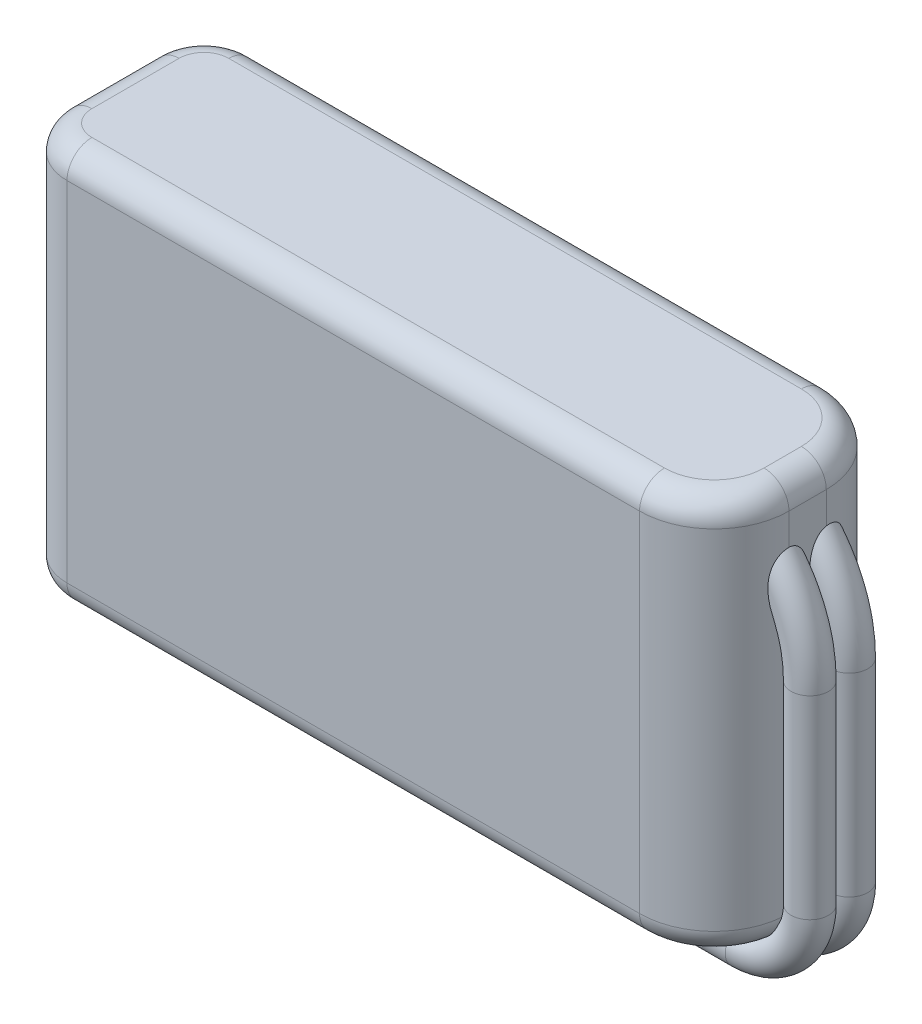
from build123d import *

# Parameters (mm, degrees)
SKETCH1_W           = 56
SKETCH1_H           = 15
BOSS_EXTRUDE1_DEPTH = 32
FILLET1_R           = 4
FILLET2_R           = 6
FILLET3_R           = 2
SKETCH4_R           = 1.5


with BuildPart() as part:
    # Sketch1 → Boss-Extrude1 (new body)
    with BuildSketch(Plane(origin=(0, 0, 0), x_dir=(1, 0, 0), z_dir=(0, 1, 0))):
        Rectangle(SKETCH1_W, SKETCH1_H)
    extrude(amount=BOSS_EXTRUDE1_DEPTH)

    # Fillet1
    fillet1_edges = [part.edges().sort_by_distance(p)[0] for p in [
        (-28, 16, 7.5),
        (-28, 16, -7.5),
    ]]
    fillet(fillet1_edges, radius=FILLET1_R)

    # Fillet2
    fillet2_edges = [part.edges().sort_by_distance(p)[0] for p in [
        (28, 16, 7.5),
        (28, 16, -7.5),
    ]]
    fillet(fillet2_edges, radius=FILLET2_R)

    # Fillet3
    fillet3_edges = [part.edges().sort_by_distance(p)[0] for p in [
        (-28, 0, 0),
        (-28, 32, 0),
        (-1, 0, 7.5),
        (-26.828427125, 0, 6.328427125),
        (-26.828427125, 0, -6.328427125),
        (-1, 32, 7.5),
        (-26.828427125, 32, 6.328427125),
        (-26.828427125, 32, -6.328427125),
        (-1, 0, -7.5),
        (-1, 32, -7.5),
        (28, 0, 0),
        (26.242640687, 0, 5.742640687),
        (26.242640687, 0, -5.742640687),
        (28, 32, 0),
        (26.242640687, 32, 5.742640687),
        (26.242640687, 32, -5.742640687),
    ]]
    fillet(fillet3_edges, radius=FILLET3_R)

    # Sweep2: sweep along a path in Sketch3
    with BuildLine(Plane(origin=(0, 0, -7.5), x_dir=(-1, 0, 0), z_dir=(0, 0, -1))) as sweep2_path:
        Line((0, -2.523571647), (-24.380909243, -2.523571647))
        ThreePointArc((-24.380909243, -2.523571647), (-28.616108457, -0.769294693), (-30.370385411, 3.465904521))
        Line((-30.370385411, 3.465904521), (-30.370385411, 19.042947176))
        ThreePointArc((-30.370385411, 19.042947176), (-28.424943012, 25.584575861), (-23.220936705, 30))
    # Sketch4 → Sweep2 (sweep)
    with BuildSketch(Plane(origin=(0, 0, 0), x_dir=(0, 0, -1), z_dir=(1, 0, 0))):
        with Locations((1.656570637, -1.831459883)):
            Circle(SKETCH4_R)
        with Locations((-1.5, -1.831459883)):
            Circle(SKETCH4_R)
    sweep(path=sweep2_path.line)


solid = part.part
